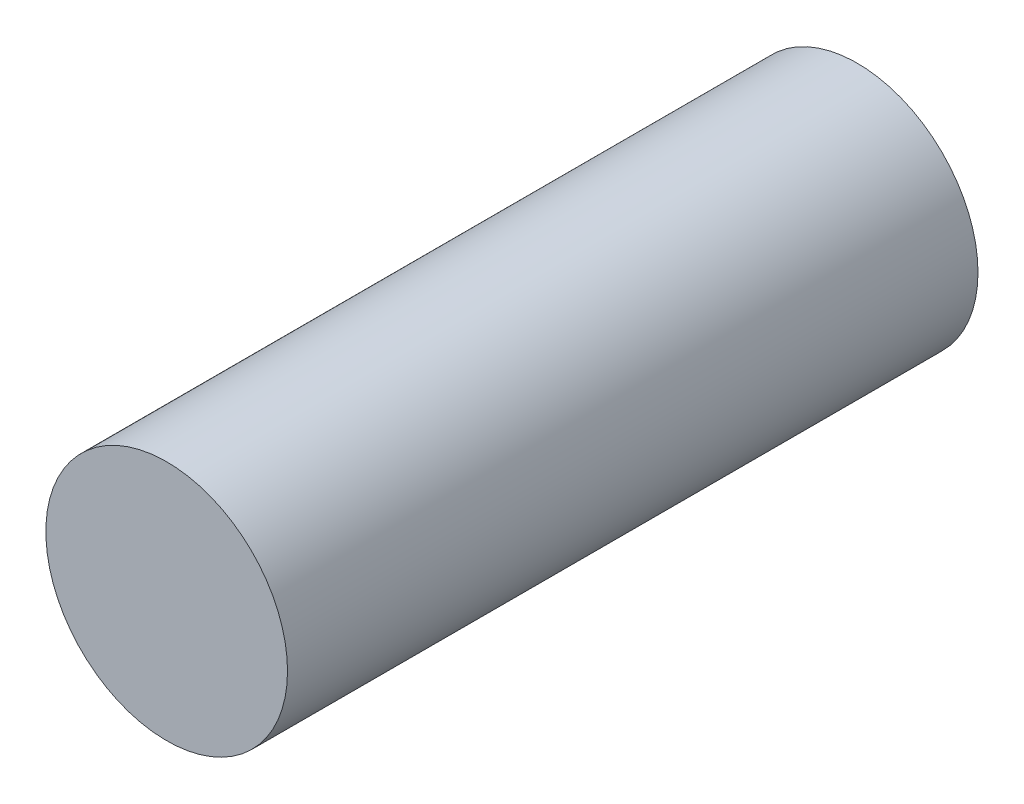
from build123d import *

# Parameters (mm, degrees)
CROQUIS1_R              = 17.5
SALIENTE_EXTRUIR1_DEPTH = 100


with BuildPart() as part:
    # Croquis1 → Saliente-Extruir1 (new body)
    with BuildSketch(Plane.XY):
        Circle(CROQUIS1_R)
    extrude(amount=SALIENTE_EXTRUIR1_DEPTH)


solid = part.part
